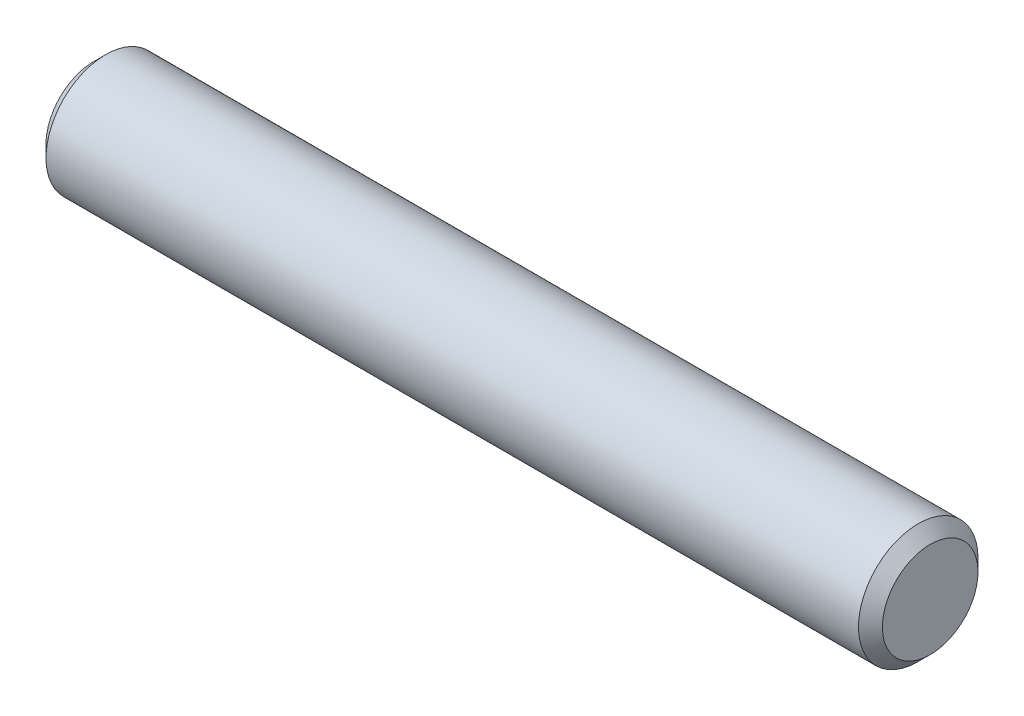
from build123d import *

# Parameters (mm, degrees)
SKETCH2_R           = 1.5875
EXTRUDE1_DEPTH      = 11.1125
EXTRUDE1_DEPTH_BACK = 11.1125
CHAMFER1_SIZE       = 0.3175


with BuildPart() as part:
    # Sketch2 → Extrude1 (new body, two sides)
    with BuildSketch(Plane(origin=(0, 0, 0), x_dir=(0, 0, -1), z_dir=(1, 0, 0))) as extrude1_sk:
        Circle(SKETCH2_R)
    extrude(amount=EXTRUDE1_DEPTH)
    extrude(extrude1_sk.sketch, amount=-EXTRUDE1_DEPTH_BACK)

    # Chamfer1
    chamfer1_edges = [part.edges().sort_by_distance(p)[0] for p in [
        (-11.1125, 0, 1.5875),
        (11.1125, 0, 1.5875),
    ]]
    chamfer(chamfer1_edges, length=CHAMFER1_SIZE)


solid = part.part
